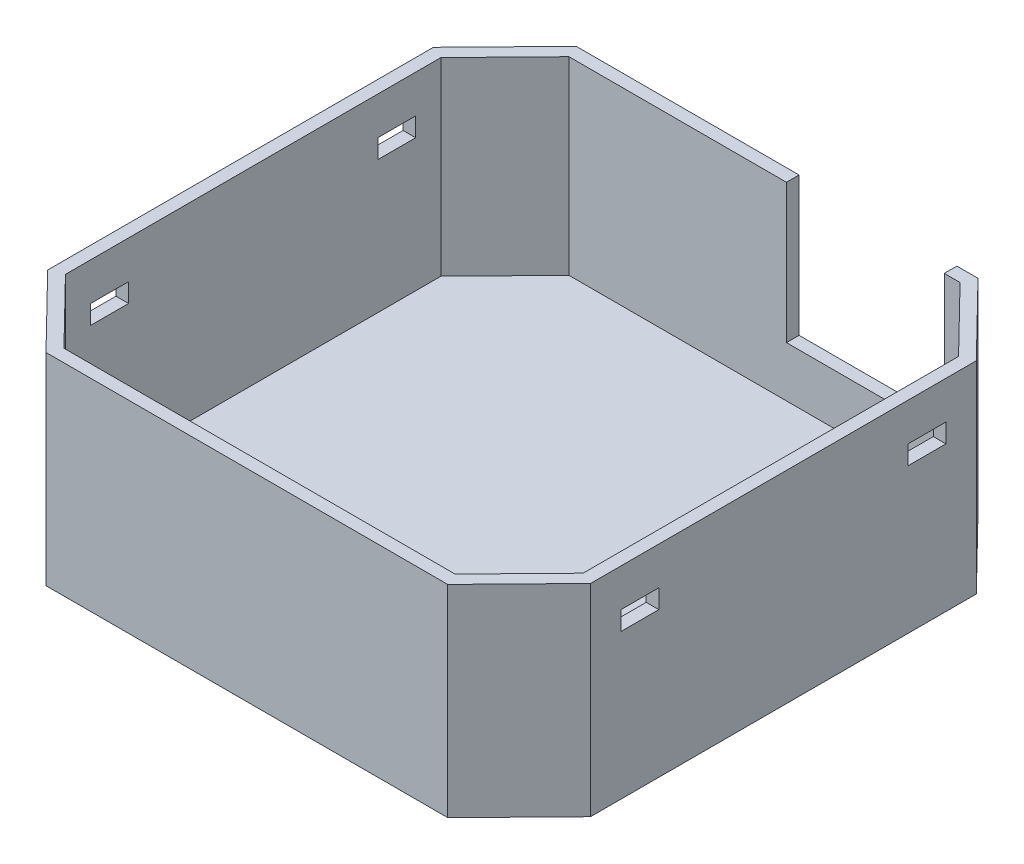
from build123d import *

# Parameters (mm, degrees)
BOSS_EXTRUDE1_DEPTH     = 16
CUT_EXTRUDE1_DEPTH      = 15
SKETCH3_R               = 1.002930515
SKETCH3_W               = 12.5
SKETCH3_H               = 1
CUT_EXTRUDE2_DEPTH      = 11
SKETCH4_W               = 3
SKETCH4_H               = 1.5
CUT_EXTRUDE3_DEPTH      = 1
CUT_EXTRUDE3_DEPTH_BACK = 44
SKETCH5_R               = 1
SKETCH5_R_2             = 0.75
CUT_EXTRUDE4_DEPTH      = 1


with BuildPart() as part:
    # Sketch1 → Boss-Extrude1 (new body)
    with BuildSketch(Plane(origin=(0, 0, 0), x_dir=(1, 0, 0), z_dir=(0, 1, 0))):
        Polygon((-21.5, 15.276990566), (-15.910083809, 21), (15.910083809, 21), (21.5, 15.276990566), (21.5, -15.276990566), (15.910083809, -21), (-15.910083809, -21), (-21.5, -15.276990566), align=None)
    extrude(amount=BOSS_EXTRUDE1_DEPTH)

    # Sketch2 → Cut-Extrude1 (cut)
    with BuildSketch(Plane(origin=(0, 16, 0), x_dir=(1, 0, 0), z_dir=(0, 1, 0))):
        Polygon((-15.488962048, 20), (-20.5, 14.869651621), (-20.5, -14.869651621), (-15.488962048, -20), (15.488962048, -20), (20.5, -14.869651621), (20.5, 14.869651621), (15.488962048, 20), align=None)
    extrude(amount=-CUT_EXTRUDE1_DEPTH, mode=Mode.SUBTRACT)

    # Sketch3 → Cut-Extrude2 (cut)
    with BuildSketch(Plane(origin=(0, 16, 0), x_dir=(1, 0, 0), z_dir=(0, 1, 0))):
        with Locations((16.5, 12.271619794)):
            Circle(SKETCH3_R)
        with Locations((7.988962048, 20.5)):
            Rectangle(SKETCH3_W, SKETCH3_H)
    extrude(amount=-CUT_EXTRUDE2_DEPTH, mode=Mode.SUBTRACT)

    # Sketch4 → Cut-Extrude3 (cut, two sides)
    with BuildSketch(Plane.ZY.offset(21.5)) as cut_extrude3_sk:
        with Locations((-11.369651621, 12.25)):
            Rectangle(SKETCH4_W, SKETCH4_H)
        with Locations((11.369651621, 12.25)):
            Rectangle(SKETCH4_W, SKETCH4_H)
    extrude(amount=CUT_EXTRUDE3_DEPTH, mode=Mode.SUBTRACT)
    extrude(cut_extrude3_sk.sketch, amount=-CUT_EXTRUDE3_DEPTH_BACK, mode=Mode.SUBTRACT)

    # Sketch5 → Cut-Extrude4 (cut)
    with BuildSketch(Plane(origin=(0, 1, 0), x_dir=(1, 0, 0), z_dir=(0, 1, 0))):
        with Locations((16, 13)):
            Circle(SKETCH5_R)
        with Locations((8.5, 17)):
            Circle(SKETCH5_R_2)
    extrude(amount=-CUT_EXTRUDE4_DEPTH, mode=Mode.SUBTRACT)


solid = part.part
